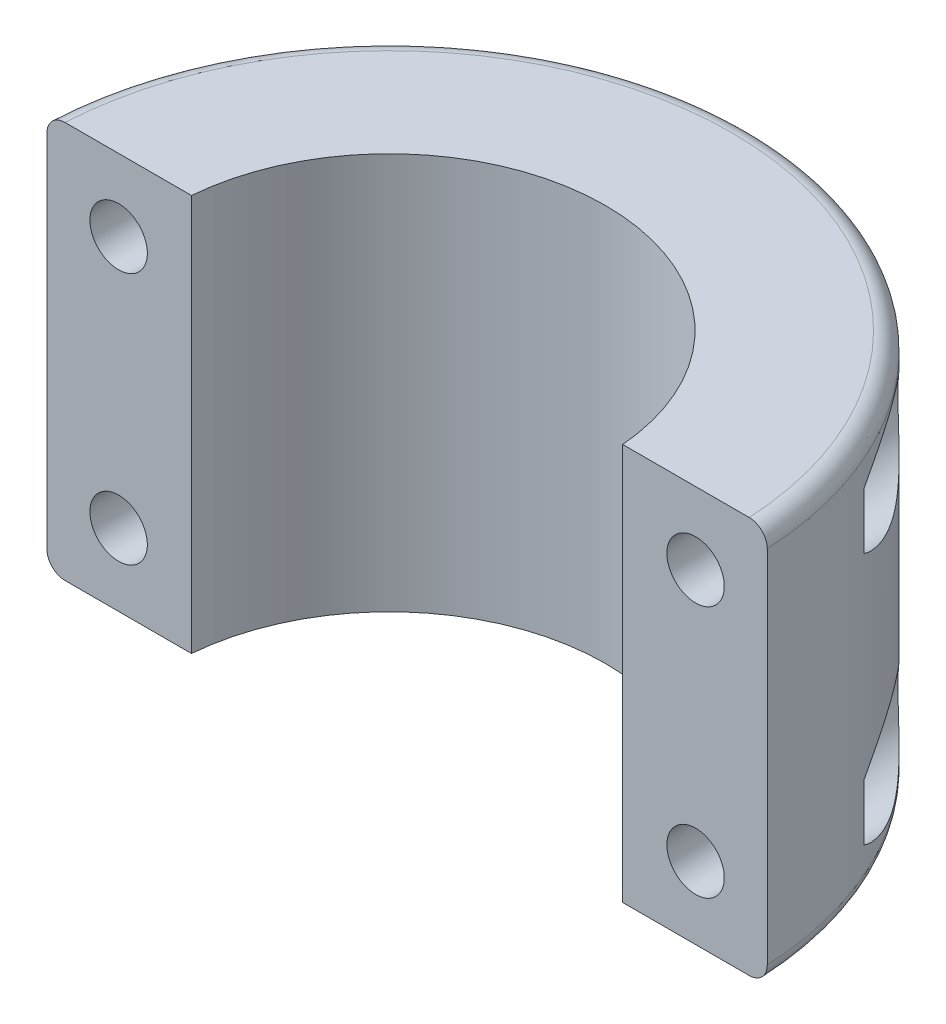
from build123d import *

# Parameters (mm, degrees)
BOSS_EXTRUDE1_DEPTH        = 34.925
F_8_0_199_DIAMETER_HOLE1_D = 5.0546
LPATTERN1_COUNT            = 2
LPATTERN1_PITCH            = 50.8
LPATTERN1_COUNT_DIR2       = 2
LPATTERN1_PITCH_DIR2       = 22.225
SKETCH5_R                  = 4.445
CUT_EXTRUDE1_DEPTH         = 19.05
LPATTERN2_COUNT            = 2
LPATTERN2_PITCH            = 50.8
LPATTERN2_COUNT_DIR2       = 2
LPATTERN2_PITCH_DIR2       = 22.225
FILLET1_R                  = 1.5875
SKETCH6_W                  = 63.605048243
SKETCH6_H                  = 35.055385684
CUT_EXTRUDE3_DEPTH         = 1.5875


with BuildPart() as part:
    # Sketch1 → Boss-Extrude1 (new body)
    with BuildSketch(Plane(origin=(0, 0, 0), x_dir=(1, 0, 0), z_dir=(0, 1, 0))):
        with BuildLine():
            Line((-19.05, 0), (-31.75, 0))
            ThreePointArc((-31.75, 0), (0, 31.75), (31.75, 0))
            Line((31.75, 0), (19.05, 0))
            ThreePointArc((19.05, 0), (0, 19.05), (-19.05, 0))
        make_face()
    extrude(amount=BOSS_EXTRUDE1_DEPTH)

    # #8 (0.199) Diameter Hole1 (through all)
    with Locations(Plane.XY):
        with Locations((-25.4, 28.575)):
            f_8_0_199_diameter_hole1 = Hole(F_8_0_199_DIAMETER_HOLE1_D / 2)

    # LPattern1: 8 _0.199_ Diameter Hole1 2 × 2
    with Locations(*[(i * LPATTERN1_PITCH, -j * LPATTERN1_PITCH_DIR2, 0) for i in range(LPATTERN1_COUNT) for j in range(LPATTERN1_COUNT_DIR2) if (i, j) != (0, 0)]):
        add(f_8_0_199_diameter_hole1, mode=Mode.SUBTRACT)

    # Sketch5 → Cut-Extrude1 (cut)
    with BuildSketch(Plane(origin=(0, 0, -31.75), x_dir=(-1, 0, 0), z_dir=(0, 0, -1))):
        with Locations((-25.4, 28.575)):
            Circle(SKETCH5_R)
    cut_extrude1 = extrude(amount=-CUT_EXTRUDE1_DEPTH, mode=Mode.SUBTRACT)

    # LPattern2: Cut-Extrude1 2 × 2
    with Locations(*[(-i * LPATTERN2_PITCH, -j * LPATTERN2_PITCH_DIR2, 0) for i in range(LPATTERN2_COUNT) for j in range(LPATTERN2_COUNT_DIR2) if (i, j) != (0, 0)]):
        add(cut_extrude1, mode=Mode.SUBTRACT)

    # Fillet1
    fillet1_edges = [part.edges().sort_by_distance(p)[0] for p in [
        (0, 34.925, -31.75),
        (0, 0, -31.75),
    ]]
    fillet(fillet1_edges, radius=FILLET1_R)

    # Sketch6 → Cut-Extrude3 (cut)
    with BuildSketch(Plane(origin=(0, 0, 0), x_dir=(-1, 0, 0), z_dir=(0, 0, -1))):
        with Locations((0.052524121, 17.397307158)):
            Rectangle(SKETCH6_W, SKETCH6_H)
    extrude(amount=CUT_EXTRUDE3_DEPTH, mode=Mode.SUBTRACT)


solid = part.part
